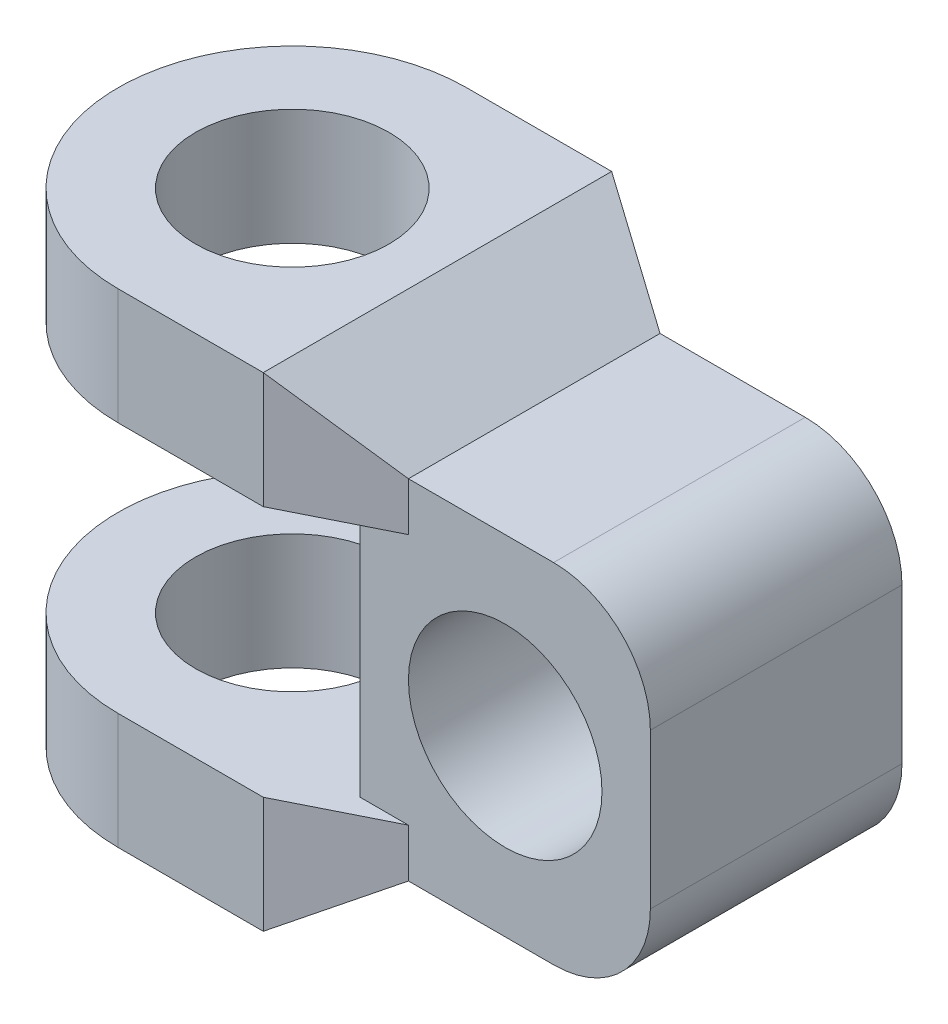
from build123d import *

# Parameters (mm, degrees)
SKETCH1_R           = 10
BOSS_EXTRUDE1_DEPTH = 50
SKETCH2_W           = 44.116747391
SKETCH2_H           = 26
CUT_EXTRUDE1_DEPTH  = 50
SKETCH3_R           = 10
CUT_EXTRUDE2_DEPTH  = 50
CUT_EXTRUDE3_DEPTH  = 36
CUT_EXTRUDE4_DEPTH  = 50
FILLET1_R           = 10
SKETCH6_W           = 2.5
SKETCH6_H           = 26
CUT_EXTRUDE5_DEPTH  = 50


with BuildPart() as part:
    # Sketch1 → Boss-Extrude1 (new body)
    with BuildSketch(Plane(origin=(0, 0, 0), x_dir=(1, 0, 0), z_dir=(0, 1, 0))):
        with BuildLine():
            Line((0, 18), (50, 18))
            Line((50, 18), (50, -18))
            Line((50, -18), (0, -18))
            ThreePointArc((0, -18), (-18, 0), (0, 18))
        make_face()
        Circle(SKETCH1_R, mode=Mode.SUBTRACT)
    extrude(amount=BOSS_EXTRUDE1_DEPTH)

    # Sketch2 → Cut-Extrude1 (cut)
    with BuildSketch(Plane(origin=(0, 0, -18), x_dir=(-1, 0, 0), z_dir=(0, 0, -1))):
        with Locations((2.058373696, 25)):
            Rectangle(SKETCH2_W, SKETCH2_H)
    extrude(amount=-CUT_EXTRUDE1_DEPTH, mode=Mode.SUBTRACT)

    # Sketch3 → Cut-Extrude2 (cut)
    with BuildSketch(Plane(origin=(0, 0, -18), x_dir=(-1, 0, 0), z_dir=(0, 0, -1))):
        with Locations((-35, 25)):
            Circle(SKETCH3_R)
    extrude(amount=-CUT_EXTRUDE2_DEPTH, mode=Mode.SUBTRACT)

    # Sketch4 → Cut-Extrude3 (cut)
    with BuildSketch(Plane(origin=(0, 0, -18), x_dir=(-1, 0, 0), z_dir=(0, 0, -1))):
        Polygon((-15, 0), (-25, 7), (-50, 7), (-50, 0), align=None)
        Polygon((-50, 50), (-50, 43), (-25, 43), (-15, 50), align=None)
    extrude(amount=-CUT_EXTRUDE3_DEPTH, mode=Mode.SUBTRACT)

    # Sketch5 → Cut-Extrude4 (cut)
    with BuildSketch(Plane(origin=(0, 50, 0), x_dir=(1, 0, 0), z_dir=(0, 1, 0))):
        Polygon((15, 18), (25, 13), (50, 13), (50, 18), align=None)
        Polygon((15, -18), (25, -13), (50, -13), (50, -18), align=None)
    extrude(amount=-CUT_EXTRUDE4_DEPTH, mode=Mode.SUBTRACT)

    # Fillet1
    fillet1_edges = [part.edges().sort_by_distance(p)[0] for p in [
        (50, 7, 0),
        (50, 43, 0),
    ]]
    fillet(fillet1_edges, radius=FILLET1_R)

    # Sketch6 → Cut-Extrude5 (cut)
    with BuildSketch(Plane.ZY.offset(-20)):
        with Locations((-14.25, 25)):
            Rectangle(SKETCH6_W, SKETCH6_H)
        with Locations((14.25, 25)):
            Rectangle(SKETCH6_W, SKETCH6_H)
    extrude(amount=-CUT_EXTRUDE5_DEPTH, mode=Mode.SUBTRACT)


solid = part.part
